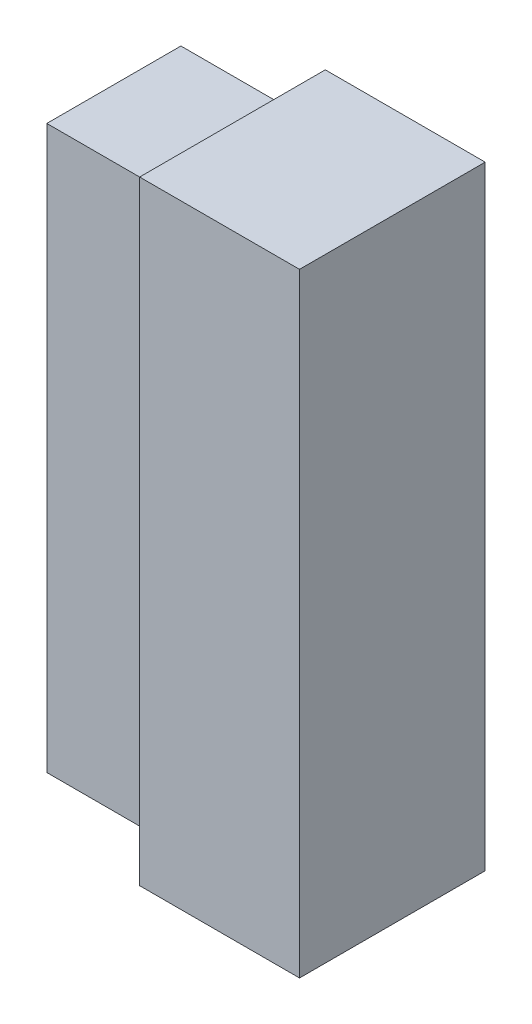
from build123d import *

# Parameters (mm, degrees)
SKETCH1_W           = 31
SKETCH1_H           = 36
BOSS_EXTRUDE1_DEPTH = 119
SKETCH2_W           = 26
SKETCH2_H           = 109
BOSS_EXTRUDE2_DEPTH = 23


with BuildPart() as part:
    # Sketch1 → Boss-Extrude1 (new body)
    with BuildSketch(Plane(origin=(0, 0, 0), x_dir=(1, 0, 0), z_dir=(0, 1, 0))):
        with Locations((15.5, -18)):
            Rectangle(SKETCH1_W, SKETCH1_H)
    extrude(amount=BOSS_EXTRUDE1_DEPTH)

    # Sketch2 → Boss-Extrude2 (add)
    with BuildSketch(Plane.ZY):
        with Locations((18, 59.5)):
            Rectangle(SKETCH2_W, SKETCH2_H)
    extrude(amount=BOSS_EXTRUDE2_DEPTH)


solid = part.part
